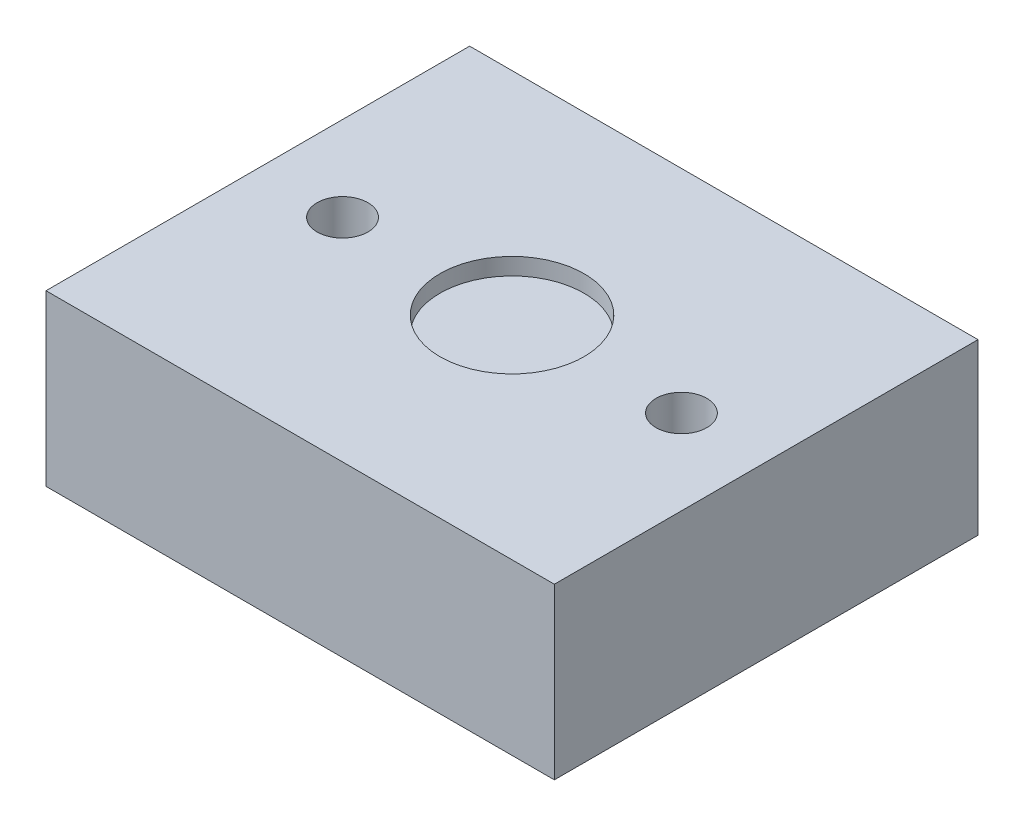
from build123d import *

# Parameters (mm, degrees)
SKETCH1_W           = 30
SKETCH1_H           = 25
SKETCH1_R           = 1.5
BOSS_EXTRUDE1_DEPTH = 10
SKETCH3_R           = 4.25
CUT_EXTRUDE1_DEPTH  = 1


with BuildPart() as part:
    # Sketch1 → Boss-Extrude1 (new body)
    with BuildSketch(Plane(origin=(0, 0, 0), x_dir=(1, 0, 0), z_dir=(0, 1, 0))):
        Rectangle(SKETCH1_W, SKETCH1_H)
        with Locations((10, 0)):
            Circle(SKETCH1_R, mode=Mode.SUBTRACT)
        with Locations((-10, 0)):
            Circle(SKETCH1_R, mode=Mode.SUBTRACT)
    extrude(amount=BOSS_EXTRUDE1_DEPTH)

    # Sketch3 → Cut-Extrude1 (cut)
    with BuildSketch(Plane(origin=(0, 10, 0), x_dir=(1, 0, 0), z_dir=(0, 1, 0))):
        Circle(SKETCH3_R)
    extrude(amount=-CUT_EXTRUDE1_DEPTH, mode=Mode.SUBTRACT)


solid = part.part
